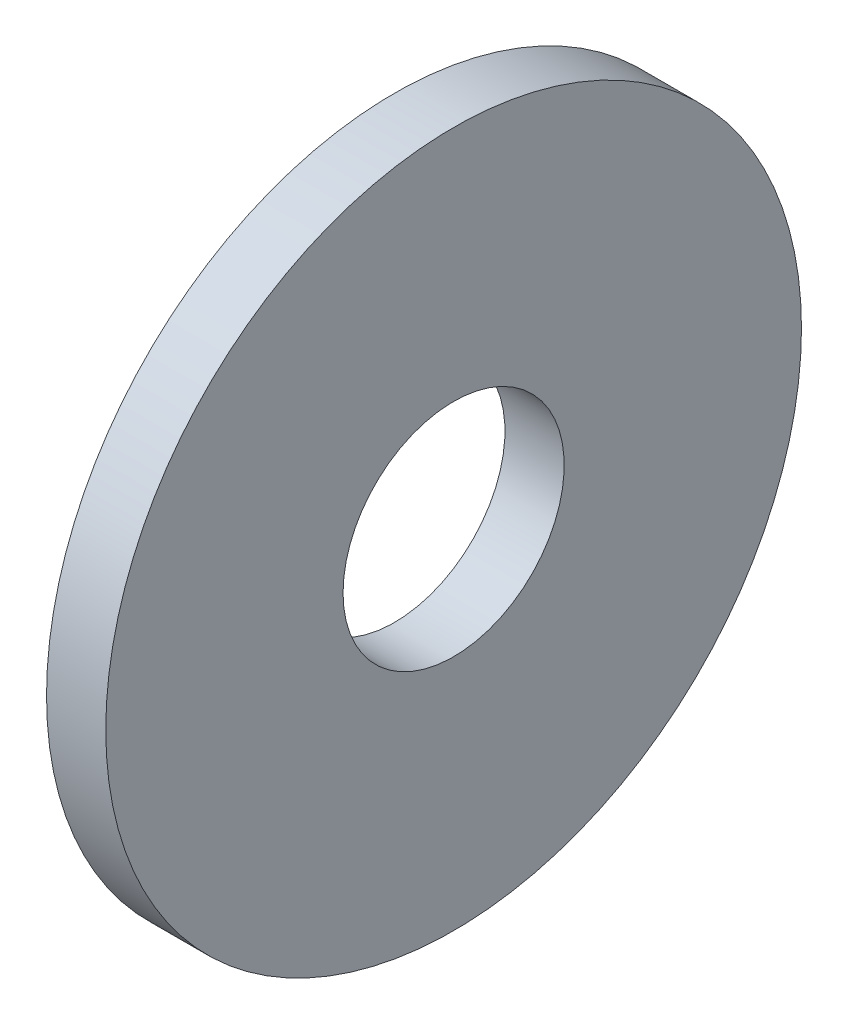
from build123d import *

# Parameters (mm, degrees)
SKETCH1_W = 3
SKETCH1_H = 12.017390092


with BuildPart() as part:
    # Sketch1 → Revolve1 (revolve)
    with BuildSketch(Plane.XY):
        with Locations((11.908906872, 9.514867924)):
            Rectangle(SKETCH1_W, SKETCH1_H)
    revolve(axis=Axis((-16.762687395, -2.093827122, 0), (1, 0, 0)))


solid = part.part
